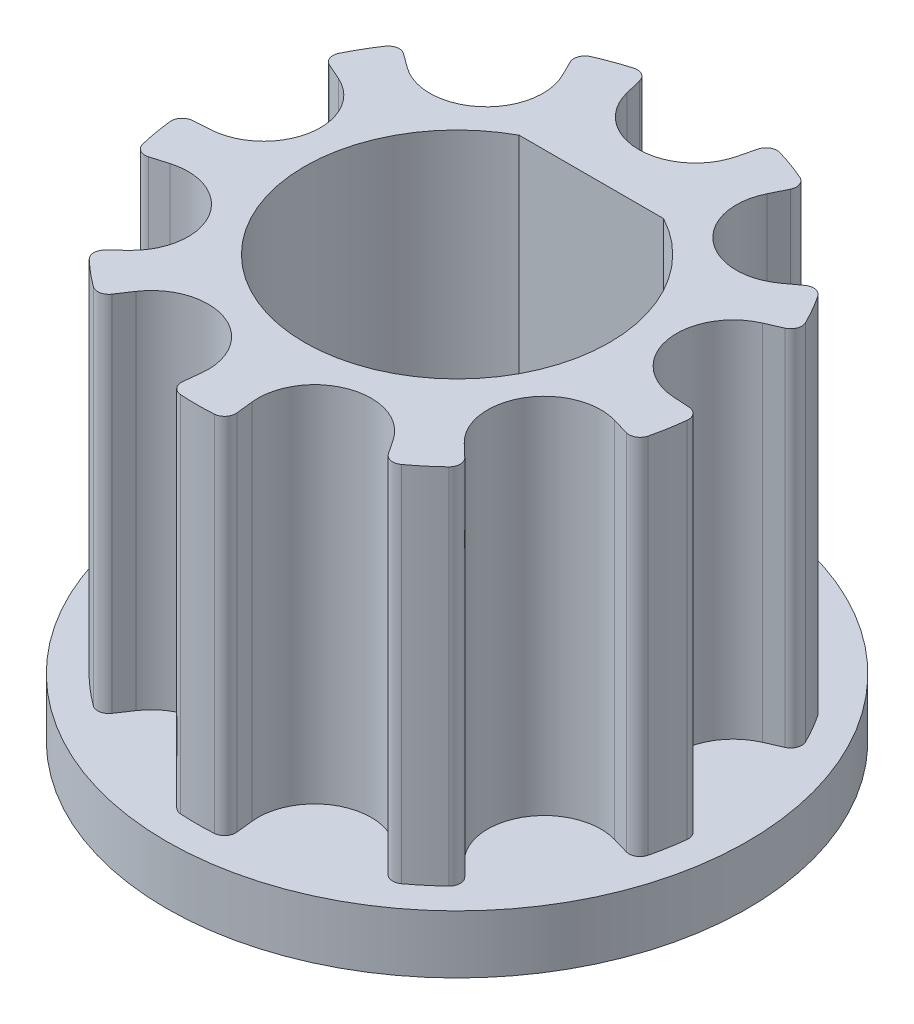
from build123d import *

# Parameters (mm, degrees)
SKETCH_1_R                       = 8
EXTRUDE_1_DEPTH                  = 1.6
SKETCH_2_R                       = 7.165
EXTRUDE_2_DEPTH                  = 10
CUT_EXTRUDE_1_DEPTH              = 17.20370328
CUT_EXTRUDE_START                = -10
CUT_EXTRUDE_2_DEPTH              = 10
FILLET_1_R                       = 0.305
PATTERN_CIRCULAR_1_COUNT         = 9
FILLET_1_OF_PATTERN_CIRCULAR_1_R = 0.305


with BuildPart() as part:
    # Эскиз1 → Бобышка-Вытянуть1 (new body)
    with BuildSketch(Plane(origin=(0, 0, 0), x_dir=(1, 0, 0), z_dir=(0, 1, 0))):
        Circle(SKETCH_1_R)
    extrude(amount=EXTRUDE_1_DEPTH)

    # Эскиз2 → Бобышка-Вытянуть2 (add)
    with BuildSketch(Plane(origin=(0, 1.6, 0), x_dir=(1, 0, 0), z_dir=(0, 1, 0))):
        Circle(SKETCH_2_R)
    extrude(amount=EXTRUDE_2_DEPTH)

    # Эскиз3 → Вырез-Вытянуть1 (cut, through all)
    with BuildSketch(Plane(origin=(0, 11.6, 0), x_dir=(1, 0, 0), z_dir=(0, 1, 0))):
        with BuildLine():
            Line((1.987460691, 3.7), (-1.987460691, 3.7))
            ThreePointArc((-1.987460691, 3.7), (-2.155535327, -3.604673002), (4.2, 0))
            ThreePointArc((4.2, 0), (3.604673002, 2.155535327), (1.987460691, 3.7))
        make_face()
    extrude(amount=-CUT_EXTRUDE_1_DEPTH, mode=Mode.SUBTRACT)

    # Эскиз4 → Вырез-Вытянуть2 (cut)
    with BuildSketch(Plane(origin=(0, 11.6, 0), x_dir=(1, 0, 0), z_dir=(0, 1, 0)).offset(CUT_EXTRUDE_START)):
        with BuildLine():
            Line((-1.702574257, 6.959774845), (-1.51531734, 6.19430692))
            ThreePointArc((-1.51531734, 6.19430692), (2.8e-08, 5.005), (1.515317353, 6.194306973))
            Line((1.515317353, 6.194306973), (1.702574257, 6.959774845))
            ThreePointArc((1.702574257, 6.959774845), (0, 7.165), (-1.702574257, 6.959774845))
        make_face()
    cut_extrude_2 = extrude(amount=CUT_EXTRUDE_2_DEPTH, mode=Mode.SUBTRACT)

    # Скругление1
    fillet_1_edges = [part.edges().sort_by_distance(p)[0] for p in [
        (-1.702574257, 6.6, -6.959774845),
        (1.702574257, 6.6, -6.959774845),
    ]]
    fillet(fillet_1_edges, radius=FILLET_1_R)

    # Круговой массив1: Вырез-Вытянуть2 ×9 about axis
    pattern_circular_1_axis = Axis((0, 0, 0), (0, 1, 0))
    for i in range(1, PATTERN_CIRCULAR_1_COUNT):
        add(cut_extrude_2.rotate(pattern_circular_1_axis, i * 360 / PATTERN_CIRCULAR_1_COUNT), mode=Mode.SUBTRACT)

    # Скругление1 of Круговой массив1
    fillet_1_of_pattern_circular_1_edges = [part.edges().sort_by_distance(p)[0] for p in [
        (-5.777904586, 6.6, -4.237103208),
        (-3.169409488, 6.6, -6.425890483),
        (-7.149689144, 6.6, 0.46815611),
        (-6.55839131, 6.6, -2.885260548),
        (-5.176054692, 6.6, 4.954359981),
        (-6.878628949, 6.6, 2.005414864),
        (-0.780486724, 6.6, 7.122363756),
        (-3.980279656, 6.6, 5.957734373),
        (3.980279656, 6.6, 5.957734373),
        (0.780486724, 6.6, 7.122363756),
        (6.878628949, 6.6, 2.005414864),
        (5.176054692, 6.6, 4.954359981),
        (6.55839131, 6.6, -2.885260548),
        (7.149689144, 6.6, 0.46815611),
        (3.169409488, 6.6, -6.425890483),
        (5.777904586, 6.6, -4.237103208),
    ]]
    fillet(fillet_1_of_pattern_circular_1_edges, radius=FILLET_1_OF_PATTERN_CIRCULAR_1_R)


solid = part.part
